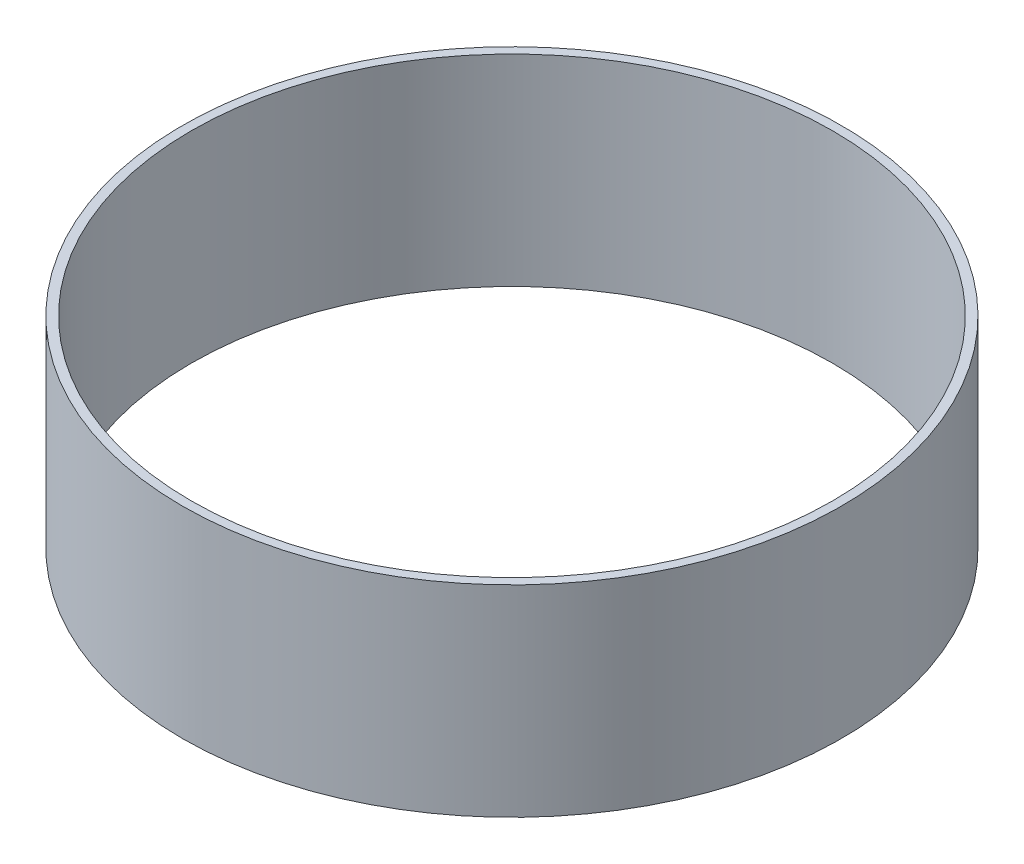
from build123d import *

# Parameters (mm, degrees)
SKETCH1_R           = 44.2
SKETCH1_R_2         = 43
BOSS_EXTRUDE1_DEPTH = 27


with BuildPart() as part:
    # Sketch1 → Boss-Extrude1 (new body)
    with BuildSketch(Plane(origin=(0, 0, 0), x_dir=(1, 0, 0), z_dir=(0, 1, 0))):
        Circle(SKETCH1_R)
        Circle(SKETCH1_R_2, mode=Mode.SUBTRACT)
    extrude(amount=BOSS_EXTRUDE1_DEPTH)


solid = part.part
